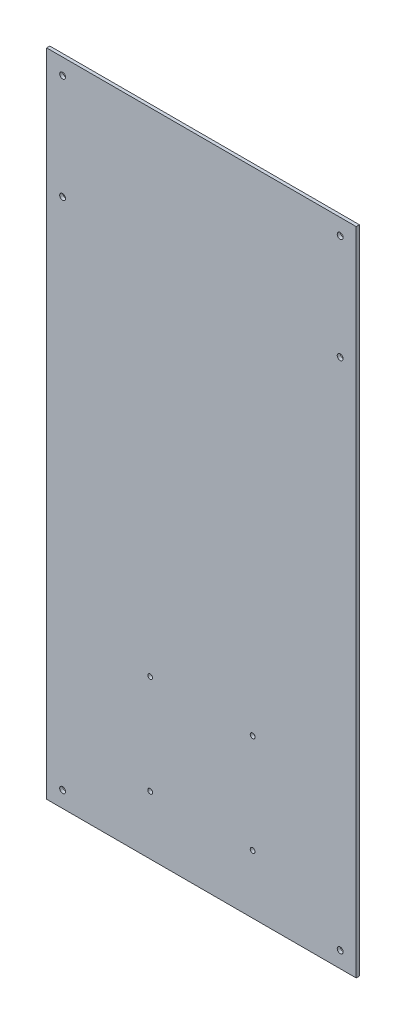
from build123d import *

# Parameters (mm, degrees)
SKETCH1_W            = 290
SKETCH1_H            = 609.6
BOSS_EXTRUDE1_DEPTH  = 3
M5_CLEARANCE_HOLE1_D = 5.5
M4_CLEARANCE_HOLE1_D = 4.5


with BuildPart() as part:
    # Sketch1 → Boss-Extrude1 (new body)
    with BuildSketch(Plane.XY):
        Rectangle(SKETCH1_W, SKETCH1_H)
    extrude(amount=BOSS_EXTRUDE1_DEPTH)

    # M5 Clearance Hole1 (through all)
    with Locations(Plane.XY.offset(3)):
        with Locations((129.995, 289.795), (-129.995, 289.795), (-129.995, -289.795), (129.995, -289.795), (129.995, 191.395), (-129.995, 191.395)):
            Hole(M5_CLEARANCE_HOLE1_D / 2)

    # M4 Clearance Hole1 (through all)
    with Locations(Plane.XY.offset(3)):
        with Locations((-48, -156.8), (-48, -249.8), (48, -249.8), (48, -156.8)):
            Hole(M4_CLEARANCE_HOLE1_D / 2)


solid = part.part
